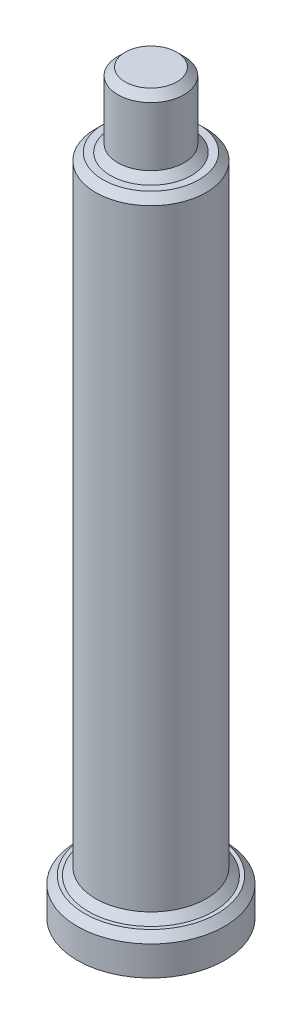
from build123d import *

# Parameters (mm, degrees)
SKETCH_1_R      = 1
SKETCH_1_R_2    = 0.75
EXTRUDE_1_DEPTH = 0.5
SKETCH_1_4_R    = 0.75
SKETCH_1_4_R_2  = 0.45
EXTRUDE_2_DEPTH = 9
SKETCH_1_6_R    = 0.45
EXTRUDE_3_DEPTH = 10
CHAMFER_3_SIZE  = 0.1
CHAMFER_4_SIZE  = 0.1
CHAMFER_5_SIZE  = 0.1


with BuildPart() as part:
    # 草图1 → 凸台-拉伸1 (new body)
    with BuildSketch(Plane(origin=(0, 0, 0), x_dir=(1, 0, 0), z_dir=(0, 1, 0))):
        Circle(SKETCH_1_R)
        Circle(SKETCH_1_R_2, mode=Mode.SUBTRACT)
    extrude(amount=EXTRUDE_1_DEPTH)

    # 草图1<4> → 凸台-拉伸2 (add)
    with BuildSketch(Plane(origin=(0, 0, 0), x_dir=(1, 0, 0), z_dir=(0, 1, 0))):
        Circle(SKETCH_1_4_R)
        Circle(SKETCH_1_4_R_2, mode=Mode.SUBTRACT)
    extrude(amount=EXTRUDE_2_DEPTH)

    # 草图1<6> → 凸台-拉伸3 (add)
    with BuildSketch(Plane(origin=(0, 0, 0), x_dir=(1, 0, 0), z_dir=(0, 1, 0))):
        Circle(SKETCH_1_6_R)
    extrude(amount=EXTRUDE_3_DEPTH)

    # 倒角3
    chamfer_3_edges = [part.edges().sort_by_distance(p)[0] for p in [
        (-0.45, 10, 0),
    ]]
    chamfer(chamfer_3_edges, length=CHAMFER_3_SIZE)

    # 倒角4
    chamfer_4_edges = [part.edges().sort_by_distance(p)[0] for p in [
        (-1, 0.5, 0),
        (-0.75, 0.5, 0),
    ]]
    chamfer(chamfer_4_edges, length=CHAMFER_4_SIZE)

    # 倒角5
    chamfer_5_edges = [part.edges().sort_by_distance(p)[0] for p in [
        (-0.75, 9, 0),
        (-0.45, 9, 0),
    ]]
    chamfer(chamfer_5_edges, length=CHAMFER_5_SIZE)


solid = part.part
